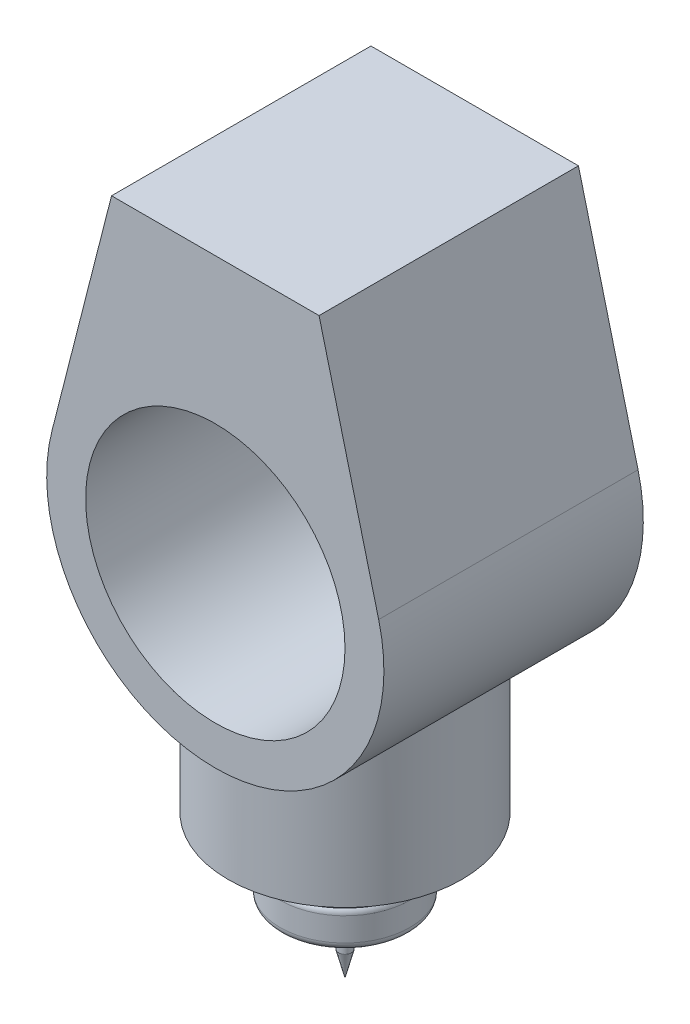
from build123d import *

# Parameters (mm, degrees)
FILLET1_R                = 3
FILLET2_R                = 3
SKETCH2_R                = 50
BOSS_EXTRUDE1_DEPTH      = 50
BOSS_EXTRUDE3_REACH      = 228.208
BOSS_EXTRUDE3_END_RADIUS = 65
SKETCH3_R                = 45
SKETCH4_R                = 32.5
BOSS_EXTRUDE4_DEPTH      = 10
FILLET3_R                = 2
FILLET4_R                = 2
SKETCH5_R                = 4
CUT_EXTRUDE1_DEPTH       = 5
CIRPATTERN1_COUNT        = 6


with BuildPart() as part:
    # Sketch1 → Revolve1 (revolve)
    with BuildSketch(Plane.XY, mode=Mode.PRIVATE) as revolve1_sk:
        Polygon((0, 15.260542724), (-20, 15.260542724), (-20, 1.260542724), (-25, 1.260542724), (-25, -13.739457276), (-10, -13.739457276), (-5, -22.399711314), (-2.5, -22.399711314), (-2.5, -30.399711314), (0, -40.08216968), align=None)
    revolve(revolve1_sk.sketch.rotate(Axis((0, -45.711991755, 0), (0, 1, 0)), 270), axis=Axis((0, -45.711991755, 0), (0, 1, 0)))

    # Fillet1
    fillet1_edges = [part.edges().sort_by_distance(p)[0] for p in [
        (0, 1.260542724, 20),
    ]]
    fillet(fillet1_edges, radius=FILLET1_R)

    # Fillet2
    fillet2_edges = [part.edges().sort_by_distance(p)[0] for p in [
        (0, -13.739457276, 25),
        (0, 1.260542724, 25),
    ]]
    fillet(fillet2_edges, radius=FILLET2_R)



with BuildPart() as body_2:
    # Sketch2 → Boss-Extrude1 (new, symmetric)
    with BuildSketch(Plane.XY):
        with BuildLine():
            Line((40, 226.080432899), (-40, 226.080432899))
            Line((-40, 226.080432899), (-62.979517923, 136.080432899))
            ThreePointArc((-62.979517923, 136.080432899), (0, 55), (62.979517923, 136.080432899))
            Line((62.979517923, 136.080432899), (40, 226.080432899))
        make_face()
        with Locations((0, 120)):
            Circle(SKETCH2_R, mode=Mode.SUBTRACT)
    extrude(amount=BOSS_EXTRUDE1_DEPTH, both=True)


with BuildPart() as part_1:
    add(part.part)

    add(body_2.part)  # Boss-Extrude3 merges body 2
    # Boss-Extrude3: up to this cylinder (the profile starts outside it)
    boss_extrude3_end = Plane(origin=(0, 120, 0), z_dir=(0, 0, -1)) * Cylinder(BOSS_EXTRUDE3_END_RADIUS, 587.416, mode=Mode.PRIVATE)
    # Sketch3 → Boss-Extrude3 (add, up to the surface)
    with BuildSketch(Plane(origin=(0, 15.260542724, 0), x_dir=(1, 0, 0), z_dir=(0, 1, 0)), mode=Mode.PRIVATE) as boss_extrude3_sk1:
        with Locations(Location((0, 0, 0), (0, 0, 90))):
            Circle(SKETCH3_R)
    boss_extrude3_tool1 = extrude(boss_extrude3_sk1.sketch, amount=BOSS_EXTRUDE3_REACH, mode=Mode.PRIVATE) - boss_extrude3_end
    add(boss_extrude3_tool1.solids().sort_by_distance((0, 15.260543, 0))[0])

    # Sketch4 → Boss-Extrude4 (add)
    with BuildSketch(Plane.XZ.offset(-15.260542724)):
        with Locations(Location((0, 0, 0), (0, 0, 90))):
            Circle(SKETCH4_R)
    extrude(amount=BOSS_EXTRUDE4_DEPTH)

    # Fillet3
    fillet3_edges = [part_1.edges().sort_by_distance(p)[0] for p in [
        (0, 15.260542724, -32.5),
    ]]
    fillet(fillet3_edges, radius=FILLET3_R)

    # Fillet4
    fillet4_edges = [part_1.edges().sort_by_distance(p)[0] for p in [
        (0, 5.260542724, -32.5),
    ]]
    fillet(fillet4_edges, radius=FILLET4_R)

    # Sketch5 → Cut-Extrude1 (cut)
    with BuildSketch(Plane.XZ.offset(-15.260542724)):
        with Locations(Location((0, 40, 0), (0, 0, 270))):
            Circle(SKETCH5_R)
    cut_extrude1 = extrude(amount=-CUT_EXTRUDE1_DEPTH, mode=Mode.SUBTRACT)

    # CirPattern1: Cut-Extrude1 ×6 about axis
    cirpattern1_axis = Axis((0, 0, 0), (0, 1, 0))
    for i in range(1, CIRPATTERN1_COUNT):
        add(cut_extrude1.rotate(cirpattern1_axis, i * 360 / CIRPATTERN1_COUNT), mode=Mode.SUBTRACT)


solid = part_1.part
